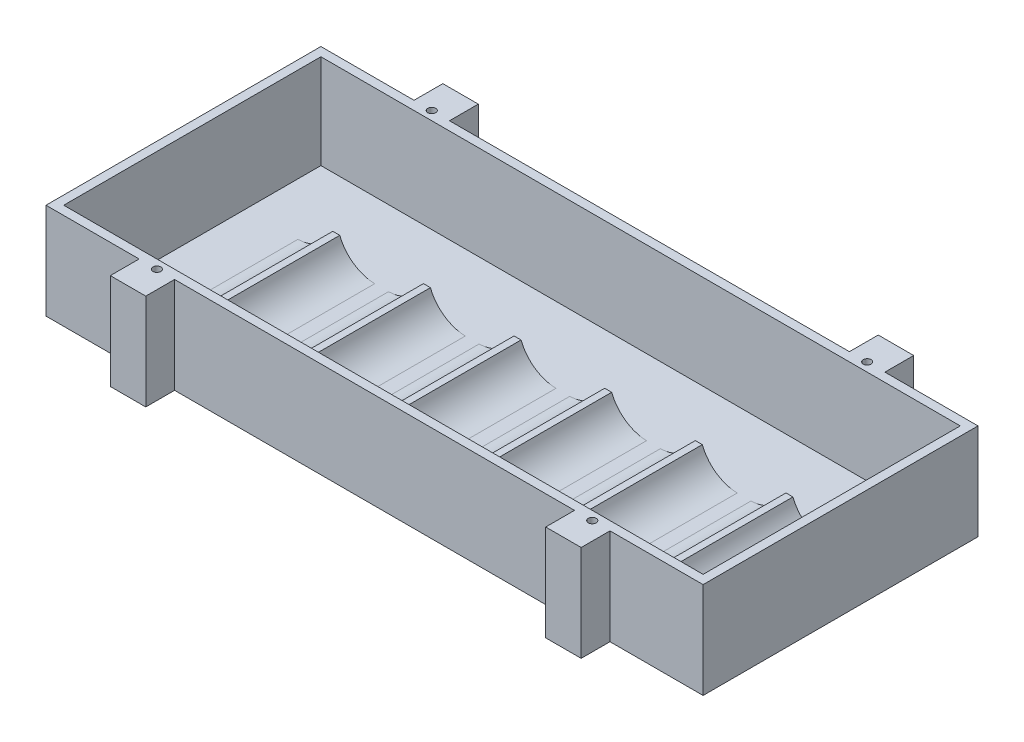
from build123d import *

# Parameters (mm, degrees)
SKETCH1_W                 = 188.214
SKETCH1_H                 = 78.74
BOSS_EXTRUDE1_DEPTH       = 0.508
SKETCH1_3_W               = 188.214
SKETCH1_3_H               = 8.255
SKETCH1_3_H_2             = 78.74
SKETCH1_3_W_2             = 183.134
SKETCH1_3_H_3             = 73.66
BOSS_EXTRUDE2_DEPTH       = 27
BOSS_EXTRUDE3_START       = 21.59
BOSS_EXTRUDE3_DEPTH       = 32.5
SKETCH1_4_W               = 188.214
SKETCH1_4_H               = 8.255
BOSS_EXTRUDE4_DEPTH       = 0.508
F_4_40_TAPPED_HOLE2_D     = 2.2606
F_4_40_TAPPED_HOLE2_DEPTH = 7.62
F_4_40_TAPPED_HOLE2_TIP   = 0.679152758
SKETCH11_W                = 114.554
SKETCH11_H                = 8.255
SKETCH11_W_2              = 26.67
CUT_EXTRUDE1_DEPTH        = 28.508


with BuildPart() as part:
    # Sketch1 → Boss-Extrude1 (new body)
    with BuildSketch(Plane(origin=(0, 0, 0), x_dir=(1, 0, 0), z_dir=(0, 1, 0))):
        with Locations((94.107, -39.37)):
            Rectangle(SKETCH1_W, SKETCH1_H)
    extrude(amount=-BOSS_EXTRUDE1_DEPTH)

    # Sketch1_3 → Boss-Extrude2 (add)
    with BuildSketch(Plane(origin=(0, 0, 0), x_dir=(1, 0, 0), z_dir=(0, 1, 0))):
        with Locations((94.107, 4.1275)):
            Rectangle(SKETCH1_3_W, SKETCH1_3_H)
        with Locations((94.107, -82.8675)):
            Rectangle(SKETCH1_3_W, SKETCH1_3_H)
        with Locations((94.107, -39.37)):
            Rectangle(SKETCH1_3_W, SKETCH1_3_H_2)
        with Locations((94.107, -39.37)):
            Rectangle(SKETCH1_3_W_2, SKETCH1_3_H_3, mode=Mode.SUBTRACT)
    extrude(amount=BOSS_EXTRUDE2_DEPTH)

    # Sketch5 → Boss-Extrude3 (add)
    with BuildSketch(Plane.XY.offset(2.54).offset(BOSS_EXTRUDE3_START)):
        with BuildLine():
            Line((29.54, 7), (27.54, 7))
            ThreePointArc((27.54, 7), (23.600043647, 1.985651932), (17.54, 0))
            Line((17.54, 0), (39.54, 0))
            ThreePointArc((39.54, 0), (33.479956353, 1.985651932), (29.54, 7))
        make_face()
        with BuildLine():
            Line((55.4988, 7), (53.4988, 7))
            ThreePointArc((53.4988, 7), (49.558843647, 1.985651932), (43.4988, 0))
            Line((43.4988, 0), (65.4988, 0))
            ThreePointArc((65.4988, 0), (59.438756353, 1.985651932), (55.4988, 7))
        make_face()
        with BuildLine():
            Line((81.4576, 7), (79.4576, 7))
            ThreePointArc((79.4576, 7), (75.517643647, 1.985651932), (69.4576, 0))
            Line((69.4576, 0), (91.4576, 0))
            ThreePointArc((91.4576, 0), (85.397556353, 1.985651932), (81.4576, 7))
        make_face()
        with BuildLine():
            Line((107.4164, 7), (105.4164, 7))
            ThreePointArc((105.4164, 7), (101.476443647, 1.985651932), (95.4164, 0))
            Line((95.4164, 0), (117.4164, 0))
            ThreePointArc((117.4164, 0), (111.356356353, 1.985651932), (107.4164, 7))
        make_face()
        with BuildLine():
            Line((133.3752, 7), (131.3752, 7))
            ThreePointArc((131.3752, 7), (127.435243647, 1.985651932), (121.3752, 0))
            Line((121.3752, 0), (143.3752, 0))
            ThreePointArc((143.3752, 0), (137.315156353, 1.985651932), (133.3752, 7))
        make_face()
        with BuildLine():
            Line((159.334, 7), (157.334, 7))
            ThreePointArc((157.334, 7), (153.394043647, 1.985651932), (147.334, 0))
            Line((147.334, 0), (169.334, 0))
            ThreePointArc((169.334, 0), (163.273956353, 1.985651932), (159.334, 7))
        make_face()
    extrude(amount=BOSS_EXTRUDE3_DEPTH)

    # Sketch1_4 → Boss-Extrude4 (add)
    with BuildSketch(Plane(origin=(0, 0, 0), x_dir=(1, 0, 0), z_dir=(0, 1, 0))):
        with Locations((94.107, 4.1275)):
            Rectangle(SKETCH1_4_W, SKETCH1_4_H)
        with Locations((94.107, -82.8675)):
            Rectangle(SKETCH1_4_W, SKETCH1_4_H)
    extrude(amount=-BOSS_EXTRUDE4_DEPTH)

    # 4-40 Tapped Hole2
    with Locations(Plane(origin=(0, 27, 0), x_dir=(-1, 0, 0), z_dir=(0, 1, 0))):
        with Locations((-31.75, 0), (-156.464, 0), (-31.75, 78.74), (-156.464, 78.74)):
            Hole(F_4_40_TAPPED_HOLE2_D / 2, depth=F_4_40_TAPPED_HOLE2_DEPTH)
            with Locations((0, 0, -(F_4_40_TAPPED_HOLE2_DEPTH + F_4_40_TAPPED_HOLE2_TIP / 2))):  # 118° drill point
                Cone(0, F_4_40_TAPPED_HOLE2_D / 2, F_4_40_TAPPED_HOLE2_TIP, mode=Mode.SUBTRACT)

    # Sketch11 → Cut-Extrude1 (cut, through all)
    with BuildSketch(Plane(origin=(0, 27, 0), x_dir=(1, 0, 0), z_dir=(0, 1, 0))):
        with Locations((94.107, 4.1275)):
            Rectangle(SKETCH11_W, SKETCH11_H)
        with Locations((94.107, -82.8675)):
            Rectangle(SKETCH11_W, SKETCH11_H)
        with Locations((13.335, 4.1275)):
            Rectangle(SKETCH11_W_2, SKETCH11_H)
        with Locations((174.879, 4.1275)):
            Rectangle(SKETCH11_W_2, SKETCH11_H)
        with Locations((174.879, -82.8675)):
            Rectangle(SKETCH11_W_2, SKETCH11_H)
        with Locations((13.335, -82.8675)):
            Rectangle(SKETCH11_W_2, SKETCH11_H)
    extrude(amount=-CUT_EXTRUDE1_DEPTH, mode=Mode.SUBTRACT)


solid = part.part
